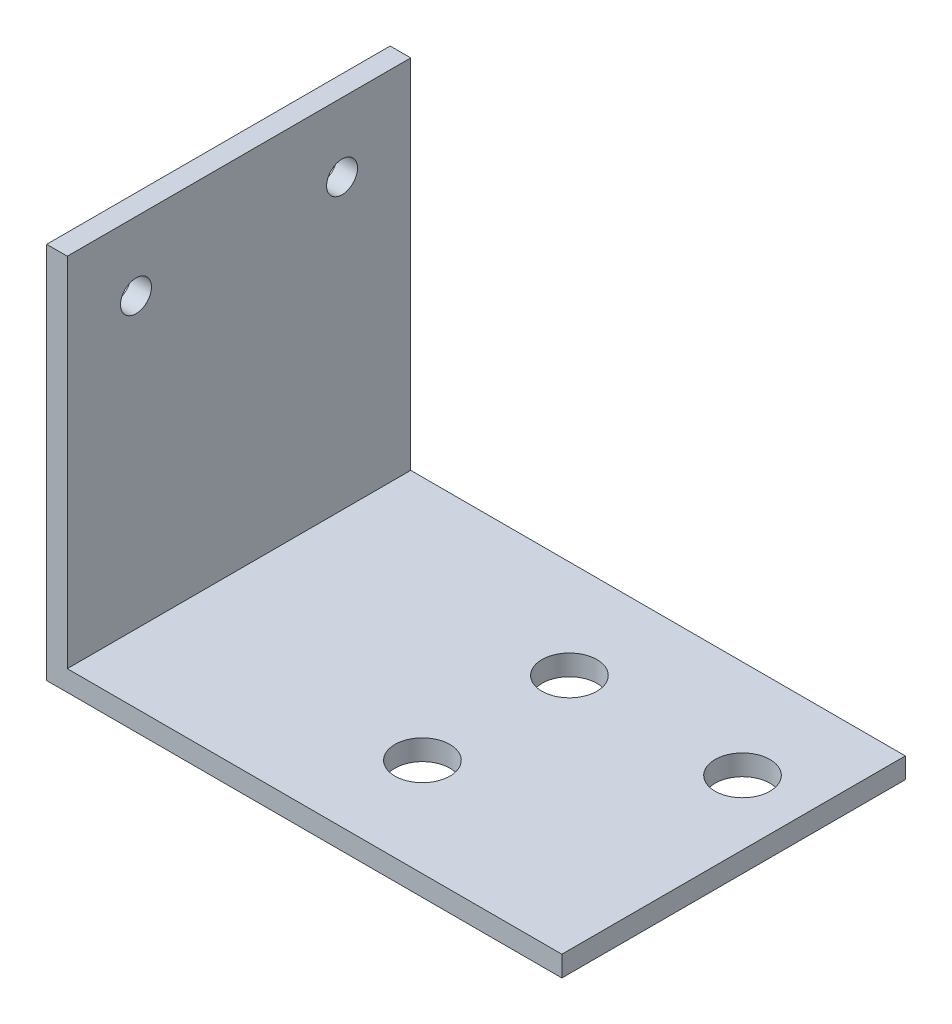
from build123d import *

# Parameters (mm, degrees)
EXTRUDE_1_DEPTH     = 50
SKETCH_6_R          = 2
CUT_EXTRUDE_2_DEPTH = 4
SKETCH1_R           = 2
CUT_EXTRUDE1_DEPTH  = 4
SKETCH2_R           = 4
CUT_EXTRUDE2_DEPTH  = 4
SKETCH4_R           = 2.25
CUT_EXTRUDE3_DEPTH  = 76


with BuildPart() as part:
    # Эскиз1 → Бобышка-Вытянуть1 (new body)
    with BuildSketch(Plane.XY):
        Polygon((0, 0), (75, 0), (75, 3), (3, 3), (3, 55), (0, 55), align=None)
    extrude(amount=EXTRUDE_1_DEPTH)

    # Эскиз6 → Вырез-Вытянуть2 (cut, through all)
    with BuildSketch(Plane(origin=(0, 3, 0), x_dir=(1, 0, 0), z_dir=(0, 1, 0))):
        with Locations((40.4, -14.3)):
            Circle(SKETCH_6_R)
        with Locations((40.4, -35.7)):
            Circle(SKETCH_6_R)
    extrude(amount=-CUT_EXTRUDE_2_DEPTH, mode=Mode.SUBTRACT)

    # Sketch1 → Cut-Extrude1 (cut, through all)
    with BuildSketch(Plane(origin=(0, 3, 0), x_dir=(1, 0, 0), z_dir=(0, 1, 0))):
        with Locations((65.6, -14.3)):
            Circle(SKETCH1_R)
    extrude(amount=-CUT_EXTRUDE1_DEPTH, mode=Mode.SUBTRACT)

    # Sketch2 → Cut-Extrude2 (cut, through all)
    with BuildSketch(Plane(origin=(0, 3, 0), x_dir=(1, 0, 0), z_dir=(0, 1, 0))):
        with Locations((40.4, -14.3)):
            Circle(SKETCH2_R)
        with Locations((65.6, -14.3)):
            Circle(SKETCH2_R)
        with Locations((40.4, -35.7)):
            Circle(SKETCH2_R)
    extrude(amount=-CUT_EXTRUDE2_DEPTH, mode=Mode.SUBTRACT)

    # Sketch4 → Cut-Extrude3 (cut, through all)
    with BuildSketch(Plane.ZY):
        with Locations((10, 45)):
            Circle(SKETCH4_R)
        with Locations((40, 45)):
            Circle(SKETCH4_R)
    extrude(amount=-CUT_EXTRUDE3_DEPTH, mode=Mode.SUBTRACT)


solid = part.part
